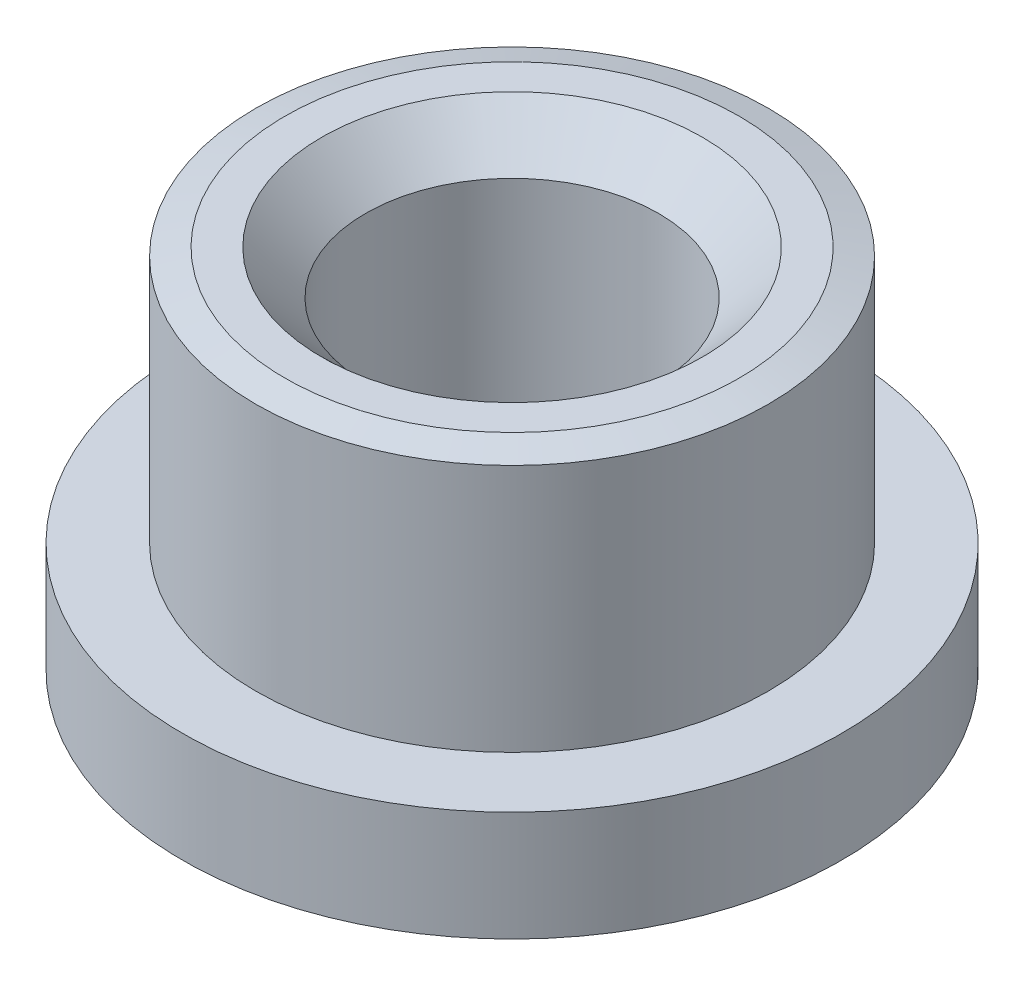
from build123d import *

# Parameters (mm, degrees)
CHAMFER_1_SIZE  = 0.8
CHAMFER_1_SIZE2 = 0.214359354
CHAMFER_2_SIZE  = 1.2


with BuildPart() as part:
    # Эскиз3 → Повернуть1 (revolve)
    with BuildSketch(Plane.XY):
        Polygon((-4, 0), (-9, 0), (-9, 3), (-7, 3), (-7, 10), (-4, 10), align=None)
    revolve(axis=Axis((0, -11.687612648, 0), (0, 1, 0)))

    # Фаска1
    chamfer_1_edges = [part.edges().sort_by_distance(p)[0] for p in [
        (7, 10, 0),
    ]]
    chamfer_1_side = [part.faces().sort_by_distance(p)[0] for p in [
        (6.802010101, 10, 0),
    ]]
    chamfer(chamfer_1_edges, length=CHAMFER_1_SIZE, length2=CHAMFER_1_SIZE2, reference=chamfer_1_side[0])

    # Фаска2
    chamfer_2_edges = [part.edges().sort_by_distance(p)[0] for p in [
        (4, 10, 0),
    ]]
    chamfer(chamfer_2_edges, length=CHAMFER_2_SIZE)


solid = part.part
